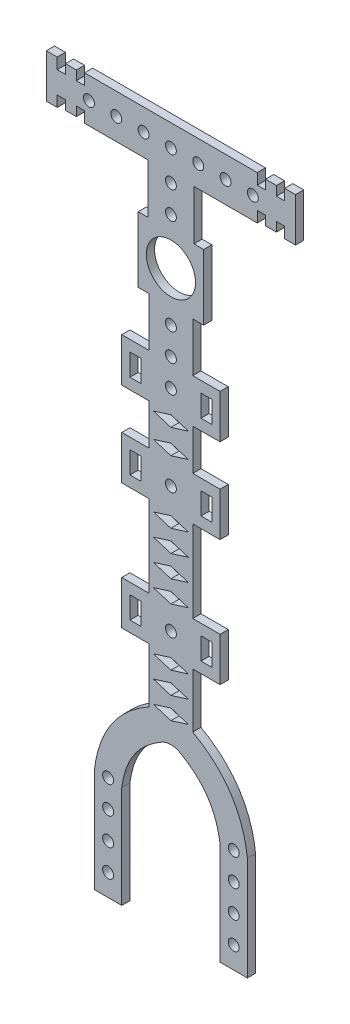
from build123d import *

# Parameters (mm, degrees)
SKETCH_1_R      = 4.5
SKETCH_1_R_2    = 1
SKETCH_1_W      = 2
SKETCH_1_H      = 4
EXTRUDE_1_DEPTH = 1.5


with BuildPart() as part:
    # 草图1 → 凸台-拉伸1 (new body)
    with BuildSketch(Plane.XY):
        Polygon((4.211145618, 7), (-4.211145618, 7), (-6, 7), (-6, -5), (-4, -5), (4, -5), (6, -5), (6, 7), align=None)
        with Locations((0, 1)):
            Circle(SKETCH_1_R, mode=Mode.SUBTRACT)
        Polygon((-4.211145618, 16.105572809), (-4.211145618, 7), (4.211145618, 7), (4.211145618, 16.105572809), (15.816086672, 16.105572809), (15.816086672, 18.105572809), (17.316086672, 18.105572809), (17.316086672, 16.405572809), (19.316086672, 16.405572809), (19.316086672, 18.105572809), (20.816086672, 18.105572809), (20.816086672, 16.105572809), (22.816086672, 16.105572809), (22.816086672, 24.1055728), (20.816086672, 24.1055728), (20.816086672, 22.1055728), (19.316086672, 22.1055728), (19.316086672, 23.8055728), (17.316086672, 23.8055728), (17.316086672, 22.1055728), (15.816086672, 22.1055728), (15.816086672, 24.1055728), (-15.816086672, 24.1055728), (-15.816086672, 22.1055728), (-17.316086672, 22.1055728), (-17.316086672, 23.8055728), (-19.316086672, 23.8055728), (-19.316086672, 22.1055728), (-20.816086672, 22.1055728), (-20.816086672, 24.1055728), (-22.816086672, 24.1055728), (-22.816086672, 16.105572809), (-20.816086672, 16.105572809), (-20.816086672, 18.105572809), (-19.316086672, 18.105572809), (-19.316086672, 16.405572809), (-17.316086672, 16.405572809), (-17.316086672, 18.105572809), (-15.816086672, 18.105572809), (-15.816086672, 16.105572809), align=None)
        with Locations((-15, 20.105572805)):
            Circle(SKETCH_1_R_2, mode=Mode.SUBTRACT)
        with Locations((-10, 20.105572805)):
            Circle(SKETCH_1_R_2, mode=Mode.SUBTRACT)
        with Locations((0, 14.54049212)):
            Circle(SKETCH_1_R_2, mode=Mode.SUBTRACT)
        with Locations((-5, 20.105572805)):
            Circle(SKETCH_1_R_2, mode=Mode.SUBTRACT)
        with Locations((0, 9.54049212)):
            Circle(SKETCH_1_R_2, mode=Mode.SUBTRACT)
        with Locations((0, 20.105572805)):
            Circle(SKETCH_1_R_2, mode=Mode.SUBTRACT)
        with Locations((5, 20.105572805)):
            Circle(SKETCH_1_R_2, mode=Mode.SUBTRACT)
        with Locations((10, 20.105572805)):
            Circle(SKETCH_1_R_2, mode=Mode.SUBTRACT)
        with Locations((15, 20.105572805)):
            Circle(SKETCH_1_R_2, mode=Mode.SUBTRACT)
        with BuildLine():
            Line((4, -5), (-4, -5))
            Line((-4, -5), (-4, -14))
            Line((-4, -14), (-9, -14))
            Line((-9, -14), (-9, -22))
            Line((-9, -22), (-4, -22))
            Line((-4, -22), (-4, -29.5))
            Line((-4, -29.5), (-9, -29.5))
            Line((-9, -29.5), (-9, -37.5))
            Line((-9, -37.5), (-4, -37.5))
            Line((-4, -37.5), (-4, -52.5))
            Line((-4, -52.5), (-9, -52.5))
            Line((-9, -52.5), (-9, -60.5))
            Line((-9, -60.5), (-4, -60.5))
            Line((-4, -60.5), (-4, -70.5))
            add(Edge.make_bspline(
                [(-4, -70.5), (-12.824800186, -75.446472906), (-14, -85.5)],
                knots=[0, 0, 0, 1, 1, 1], degree=2))
            Line((-14, -85.5), (-14, -104.5))
            Line((-14, -104.5), (-9, -104.5))
            Line((-9, -104.5), (-9, -85.807652325))
            add(Edge.make_bspline(
                [(-2.485449351, -75.423297078), (-4.422492976, -76.665182687), (-6.772437427, -79.35168045), (-8.60156745, -82.914074006), (-9, -85.807652325)],
                knots=[0.069213369, 0.069213369, 0.069213369, 0.368595186, 0.61432531, 0.982920497, 0.982920497, 0.982920497], degree=2))
            Line((-2.485449351, -75.423297078), (-3.2, -75.2))
            Line((-3.2, -75.2), (0, -74.2))
            Line((0, -74.2), (3.2, -75.2))
            Line((3.2, -75.2), (2.485449351, -75.423297078))
            add(Edge.make_bspline(
                [(2.485449351, -75.423297078), (4.422492976, -76.665182687), (6.772437427, -79.35168045), (8.60156745, -82.914074006), (9, -85.807652325)],
                knots=[0.069213369, 0.069213369, 0.069213369, 0.368595186, 0.61432531, 0.982920497, 0.982920497, 0.982920497], degree=2))
            Line((9, -85.807652325), (9, -104.5))
            Line((9, -104.5), (14, -104.5))
            Line((14, -104.5), (14, -85.5))
            add(Edge.make_bspline(
                [(4, -70.5), (12.824800186, -75.446472906), (14, -85.5)],
                knots=[0, 0, 0, 1, 1, 1], degree=2))
            Line((4, -70.5), (4, -60.5))
            Line((4, -60.5), (9, -60.5))
            Line((9, -60.5), (9, -52.5))
            Line((9, -52.5), (4, -52.5))
            Line((4, -52.5), (4, -37.5))
            Line((4, -37.5), (9, -37.5))
            Line((9, -37.5), (9, -29.5))
            Line((9, -29.5), (4, -29.5))
            Line((4, -29.5), (4, -22))
            Line((4, -22), (9, -22))
            Line((9, -22), (9, -14))
            Line((9, -14), (4, -14))
            Line((4, -14), (4, -5))
        make_face()
        with Locations((-11.5, -100.5)):
            Circle(SKETCH_1_R_2, mode=Mode.SUBTRACT)
        with Locations((-11.5, -95.5)):
            Circle(SKETCH_1_R_2, mode=Mode.SUBTRACT)
        with Locations((-11.5, -90.5)):
            Circle(SKETCH_1_R_2, mode=Mode.SUBTRACT)
        with Locations((-11.5, -85.5)):
            Circle(SKETCH_1_R_2, mode=Mode.SUBTRACT)
        with Locations((-6.5, -56.5)):
            Rectangle(SKETCH_1_W, SKETCH_1_H, mode=Mode.SUBTRACT)
        with Locations((11.5, -100.5)):
            Circle(SKETCH_1_R_2, mode=Mode.SUBTRACT)
        with Locations((11.5, -95.5)):
            Circle(SKETCH_1_R_2, mode=Mode.SUBTRACT)
        with Locations((11.5, -90.5)):
            Circle(SKETCH_1_R_2, mode=Mode.SUBTRACT)
        with Locations((11.5, -85.5)):
            Circle(SKETCH_1_R_2, mode=Mode.SUBTRACT)
        Polygon((-3.2, -71.2), (-0.8, -70.45), (-3.2, -69.7), (0, -68.7), (3.2, -69.7), (0.8, -70.45), (3.2, -71.2), (0, -72.2), align=None, mode=Mode.SUBTRACT)
        Polygon((-3.2, -67.2), (-0.8, -66.45), (-3.2, -65.7), (0, -64.7), (3.2, -65.7), (0.8, -66.45), (3.2, -67.2), (0, -68.2), align=None, mode=Mode.SUBTRACT)
        Polygon((-3.2, -63.2), (-0.8, -62.45), (-3.2, -61.7), (0, -60.7), (3.2, -61.7), (0.8, -62.45), (3.2, -63.2), (0, -64.2), align=None, mode=Mode.SUBTRACT)
        with Locations((6.5, -56.5)):
            Rectangle(SKETCH_1_W, SKETCH_1_H, mode=Mode.SUBTRACT)
        with BuildLine():
            Line((-3.2, -55.2), (0, -54.2))
            Line((0, -54.2), (3.2, -55.2))
            Line((3.2, -55.2), (0.82910367, -55.940905103))
            ThreePointArc((0.82910367, -55.940905103), (0.956322035, -56.207684819), (1, -56.5))
            ThreePointArc((1, -56.5), (-0.292315181, -57.456322035), (-0.82910367, -55.940905103))
            Line((-0.82910367, -55.940905103), (-3.2, -55.2))
        make_face(mode=Mode.SUBTRACT)
        Polygon((-3.2, -51.2), (0, -50.2), (3.2, -51.2), (0, -52.2), align=None, mode=Mode.SUBTRACT)
        Polygon((-3.2, -47.2), (0, -46.2), (3.2, -47.2), (0, -48.2), align=None, mode=Mode.SUBTRACT)
        Polygon((-3.2, -43.2), (0, -42.2), (3.2, -43.2), (0, -44.2), align=None, mode=Mode.SUBTRACT)
        with Locations((-6.5, -33.5)):
            Rectangle(SKETCH_1_W, SKETCH_1_H, mode=Mode.SUBTRACT)
        with Locations((0, -33.5)):
            Circle(SKETCH_1_R_2, mode=Mode.SUBTRACT)
        Polygon((-3.2, -27.7), (0, -26.7), (3.2, -27.7), (0, -28.7), align=None, mode=Mode.SUBTRACT)
        with Locations((-6.5, -18)):
            Rectangle(SKETCH_1_W, SKETCH_1_H, mode=Mode.SUBTRACT)
        Polygon((-3.2, -23.2), (0, -22.2), (3.2, -23.2), (0, -24.2), align=None, mode=Mode.SUBTRACT)
        with Locations((0, -13)):
            Circle(SKETCH_1_R_2, mode=Mode.SUBTRACT)
        with Locations((0, -8)):
            Circle(SKETCH_1_R_2, mode=Mode.SUBTRACT)
        Polygon((-3.2, -39.2), (0, -38.2), (3.2, -39.2), (0, -40.2), align=None, mode=Mode.SUBTRACT)
        with Locations((6.5, -33.5)):
            Rectangle(SKETCH_1_W, SKETCH_1_H, mode=Mode.SUBTRACT)
        with Locations((0, -18)):
            Circle(SKETCH_1_R_2, mode=Mode.SUBTRACT)
        with Locations((6.5, -18)):
            Rectangle(SKETCH_1_W, SKETCH_1_H, mode=Mode.SUBTRACT)
        with BuildLine():
            Line((-3.2, -75.2), (-2.485449351, -75.423297078))
            add(Edge.make_bspline(
                [(-1.555258324, -74.861563726), (-2.037628855, -75.136188505), (-2.485449351, -75.423297078)],
                knots=[0, 0, 0, 0.069213369, 0.069213369, 0.069213369], degree=2))
            add(Edge.make_bspline(
                [(-1.555258324, -74.861563726), (0, -74.152312688), (1.555258324, -74.861563726)],
                knots=[0, 0, 0, 1, 1, 1], degree=2))
            add(Edge.make_bspline(
                [(1.555258324, -74.861563726), (2.037628855, -75.136188505), (2.485449351, -75.423297078)],
                knots=[0, 0, 0, 0.069213369, 0.069213369, 0.069213369], degree=2))
            Line((2.485449351, -75.423297078), (3.2, -75.2))
            Line((3.2, -75.2), (0, -74.2))
            Line((0, -74.2), (-3.2, -75.2))
        make_face()
        Polygon((0, -62.7), (-0.8, -62.45), (-3.2, -63.2), (0, -64.2), (3.2, -63.2), (0.8, -62.45), align=None)
        Polygon((0, -66.7), (-0.8, -66.45), (-3.2, -67.2), (0, -68.2), (3.2, -67.2), (0.8, -66.45), align=None)
        Polygon((0, -70.7), (-0.8, -70.45), (-3.2, -71.2), (0, -72.2), (3.2, -71.2), (0.8, -70.45), align=None)
        with BuildLine():
            Line((3.2, -55.2), (0, -54.2))
            Line((0, -54.2), (-3.2, -55.2))
            Line((-3.2, -55.2), (-0.82910367, -55.940905103))
            ThreePointArc((-0.82910367, -55.940905103), (0, -55.5), (0.82910367, -55.940905103))
            Line((0.82910367, -55.940905103), (3.2, -55.2))
        make_face()
    extrude(amount=EXTRUDE_1_DEPTH)


solid = part.part
